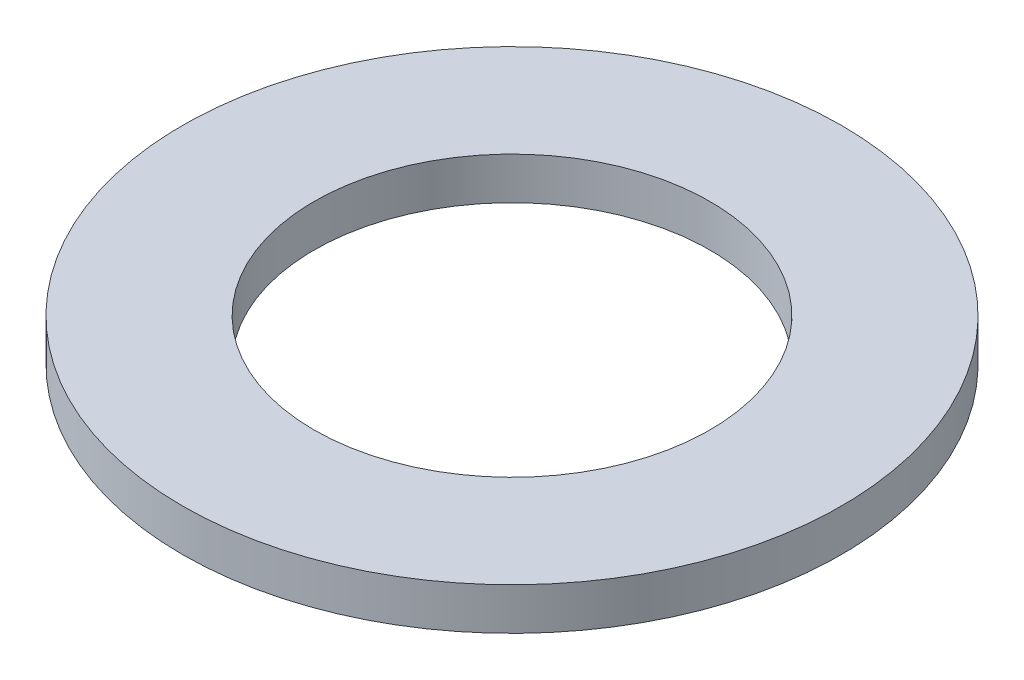
from build123d import *

# Parameters (mm, degrees)
SKETCH1_R           = 3.9751
SKETCH1_R_2         = 2.3876
BOSS_EXTRUDE1_DEPTH = 0.508


with BuildPart() as part:
    # Sketch1 → Boss-Extrude1 (new body)
    with BuildSketch(Plane(origin=(0, 0, 0), x_dir=(1, 0, 0), z_dir=(0, 1, 0))):
        Circle(SKETCH1_R)
        Circle(SKETCH1_R_2, mode=Mode.SUBTRACT)
    extrude(amount=BOSS_EXTRUDE1_DEPTH)


solid = part.part
